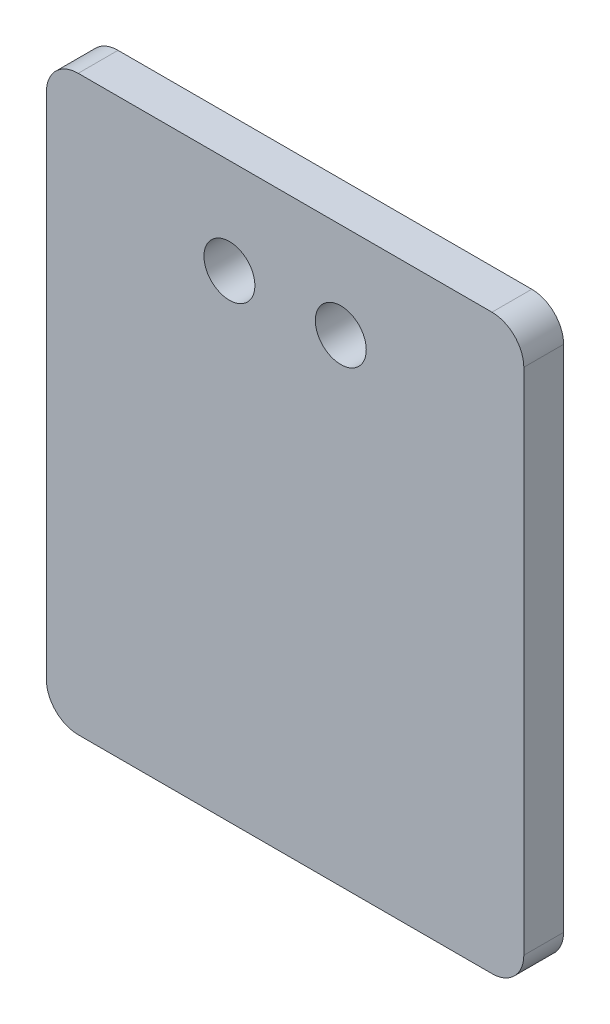
from build123d import *

# Parameters (mm, degrees)
SKETCH1_W           = 30
SKETCH1_H           = 36
SKETCH1_R           = 1.6
BOSS_EXTRUDE1_DEPTH = 2.5
FILLET1_R           = 2


with BuildPart() as part:
    # Sketch1 → Boss-Extrude1 (new body)
    with BuildSketch(Plane.XY):
        with Locations((15, -18)):
            Rectangle(SKETCH1_W, SKETCH1_H)
        with Locations((11.5, -6)):
            Circle(SKETCH1_R, mode=Mode.SUBTRACT)
        with Locations((18.5, -6)):
            Circle(SKETCH1_R, mode=Mode.SUBTRACT)
    extrude(amount=BOSS_EXTRUDE1_DEPTH)

    # Fillet1
    fillet1_edges = [part.edges().sort_by_distance(p)[0] for p in [
        (0, 0, 1.25),
        (30, 0, 1.25),
        (30, -36, 1.25),
        (0, -36, 1.25),
    ]]
    fillet(fillet1_edges, radius=FILLET1_R)


solid = part.part
